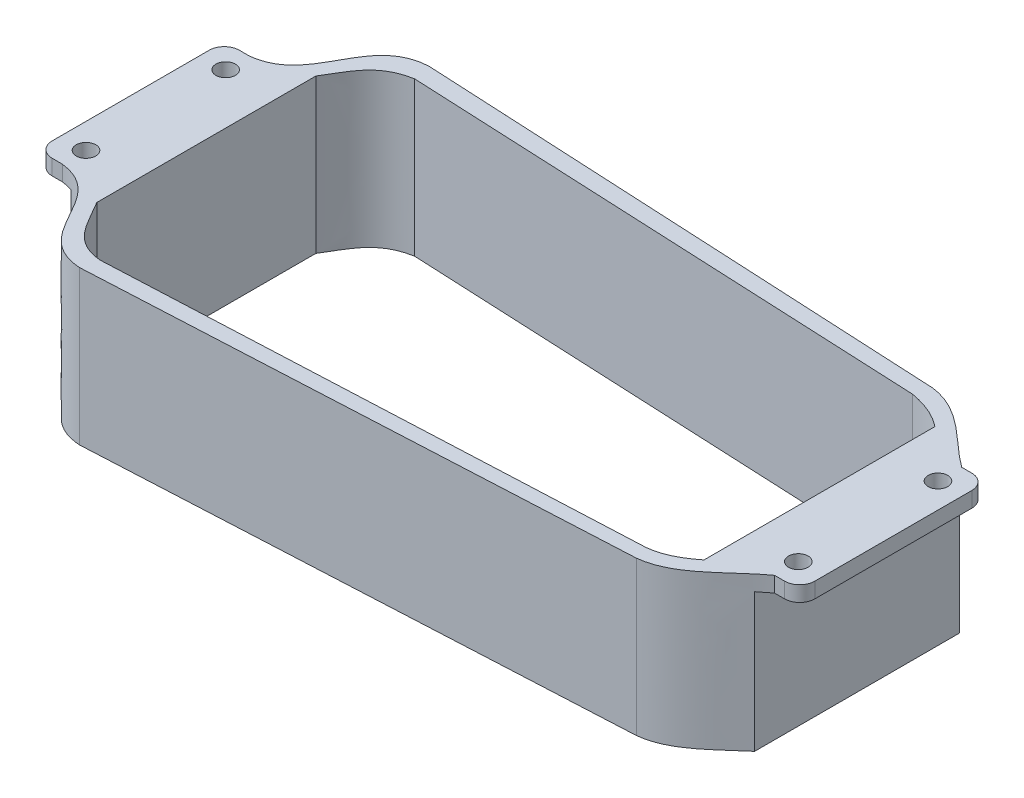
from build123d import *

# Parameters (mm, degrees)
SKETCH1_R           = 3.5
BOSS_EXTRUDE2_DEPTH = 55
SKETCH7_W           = 68.999652055
SKETCH7_H           = 50.415620377
CUT_EXTRUDE5_DEPTH  = 13
SKETCH19_W          = 74.859412742
SKETCH19_H          = 60.725118028
CUT_EXTRUDE7_DEPTH  = 13


with BuildPart() as part:
    # Sketch1 → Boss-Extrude2 (new body)
    with BuildSketch(Plane(origin=(0, 0, 0), x_dir=(1, 0, 0), z_dir=(0, 1, 0))):
        with BuildLine():
            Line((-77.08996548, -66.932643829), (112.637979465, -57.343127962))
            add(Edge.make_bspline(
                [(112.637979465, -57.343127962), (125.082628436, -56.027724614), (133.287763268, -44.662014668), (142.702606635, -37.943127962)],
                knots=[0, 0, 0, 0, 1, 1, 1, 1], degree=3))
            Line((142.702606635, -37.943127962), (146.202606635, -37.943127962))
            Line((146.202606635, -37.943127962), (146.302606635, -37.943127962))
            ThreePointArc((146.302606635, -37.943127962), (150.120983253, -36.36150458), (151.702606635, -32.543127962))
            Line((151.702606635, -32.543127962), (151.702606635, 23.656872038))
            ThreePointArc((151.702606635, 23.656872038), (150.120983253, 27.475248656), (146.302606635, 29.056872038))
            Line((146.302606635, 29.056872038), (146.202606635, 29.056872038))
            Line((146.202606635, 29.056872038), (142.702606635, 29.056872038))
            add(Edge.make_bspline(
                [(112.637979465, 48.456872038), (125.082628436, 47.14146869), (133.287763268, 35.775758744), (142.702606635, 29.056872038)],
                knots=[0, 0, 0, 0, 1, 1, 1, 1], degree=3))
            Line((112.637979465, 48.456872038), (-77.08996548, 58.046387905))
            add(Edge.make_bspline(
                [(-77.08996548, 58.046387905), (-97.502880255, 56.762508137), (-92.602876077, 31.29935649), (-112.297393365, 29.056872038)],
                knots=[0, 0, 0, 0, 1, 1, 1, 1], degree=3))
            Line((-112.297393365, 29.056872038), (-115.797393365, 29.056872038))
            Line((-115.797393365, 29.056872038), (-115.897393365, 29.056872038))
            ThreePointArc((-115.897393365, 29.056872038), (-119.715769983, 27.475248656), (-121.297393365, 23.656872038))
            Line((-121.297393365, 23.656872038), (-121.297393365, -32.543127962))
            ThreePointArc((-121.297393365, -32.543127962), (-119.715769983, -36.36150458), (-115.897393365, -37.943127962))
            Line((-115.897393365, -37.943127962), (-115.797393365, -37.943127962))
            Line((-115.797393365, -37.943127962), (-112.297393365, -37.943127962))
            add(Edge.make_bspline(
                [(-77.08996548, -66.932643829), (-97.502880255, -65.648764061), (-92.602876077, -40.185612414), (-112.297393365, -37.943127962)],
                knots=[0, 0, 0, 0, 1, 1, 1, 1], degree=3))
        make_face()
        with Locations((-112.297393365, 20.556872038)):
            Circle(SKETCH1_R, mode=Mode.SUBTRACT)
        with Locations((-112.297393365, -29.443127962)):
            Circle(SKETCH1_R, mode=Mode.SUBTRACT)
        with Locations((142.702606635, -29.443127962)):
            Circle(SKETCH1_R, mode=Mode.SUBTRACT)
        with Locations((142.702606635, 20.556872038)):
            Circle(SKETCH1_R, mode=Mode.SUBTRACT)
        with BuildLine():
            Line((-75.675939266, -60.937869235), (111.223953251, -52.297869235))
            add(Edge.make_bspline(
                [(111.223953251, -52.297869235), (116.613661153, -51.728175398), (121.119803585, -49.063877422), (125.288889488, -45.778967713)],
                knots=[0, 0, 0, 0, 0.481216011, 0.481216011, 0.481216011, 0.481216011], degree=3))
            Line((125.288889488, -45.778967713), (125.288889488, 36.892711789))
            add(Edge.make_bspline(
                [(111.223953251, 42.922130765), (116.613661153, 41.934143872), (121.119803585, 40.177621498), (125.288889488, 36.892711789)],
                knots=[0, 0, 0, 0, 0.481216011, 0.481216011, 0.481216011, 0.481216011], degree=3))
            Line((111.223953251, 42.922130765), (-75.675939266, 51.562130765))
            add(Edge.make_bspline(
                [(-75.675939266, 51.562130765), (-87.01186848, 49.517204736), (-89.586983119, 42.038204428), (-94.215939266, 34.771613311)],
                knots=[0, 0, 0, 0, 0.62412853, 0.62412853, 0.62412853, 0.62412853], degree=3))
            Line((-94.215939266, 34.771613311), (-94.215939266, -43.657869235))
            add(Edge.make_bspline(
                [(-75.675939266, -60.937869235), (-87.01186848, -60.09623443), (-89.586983119, -50.924460352), (-94.215939266, -43.657869235)],
                knots=[0, 0, 0, 0, 0.62412853, 0.62412853, 0.62412853, 0.62412853], degree=3))
        make_face(mode=Mode.SUBTRACT)
    extrude(amount=-BOSS_EXTRUDE2_DEPTH)

    # Sketch7 → Cut-Extrude5 (cut)
    with BuildSketch(Plane.ZY.offset(121.297393365)):
        with Locations((4.333112833, -30.707810189)):
            Rectangle(SKETCH7_W, SKETCH7_H)
    extrude(amount=-CUT_EXTRUDE5_DEPTH, mode=Mode.SUBTRACT)

    # Sketch19 → Cut-Extrude7 (cut)
    with BuildSketch(Plane(origin=(151.702606635, 0, 0), x_dir=(0, 0, -1), z_dir=(1, 0, 0))):
        with Locations((-5.097493458, -35.862559014)):
            Rectangle(SKETCH19_W, SKETCH19_H)
    extrude(amount=-CUT_EXTRUDE7_DEPTH, mode=Mode.SUBTRACT)


solid = part.part
